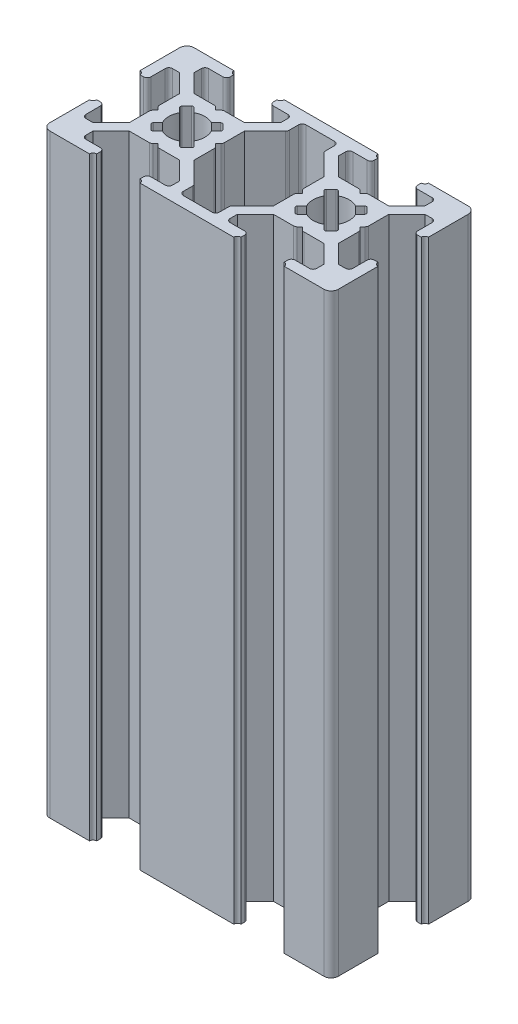
from build123d import *

# Parameters (mm, degrees)
BOSS_EXTRUDE1_DEPTH = 82.5
FILLET1_R           = 1
FILLET2_R           = 0.5
FILLET3_R           = 0.25
FILLET5_R           = 0.25
FILLET6_R           = 0.5
FILLET7_R           = 0.5
FILLET8_R           = 0.5


with BuildPart() as part:
    # Sketch2 → Boss-Extrude1 (new body)
    with BuildSketch(Plane(origin=(0, 0, 0), x_dir=(1, 0, 0), z_dir=(0, 1, 0))):
        with BuildLine():
            ThreePointArc((0, 13.5), (0.353553391, 13.353553391), (0.5, 13))
            Line((0.5, 13), (1.5, 13))
            Line((1.5, 13), (1.5, 16))
            Line((1.5, 16), (3, 16))
            Line((3, 16), (5.5, 13.5))
            Line((5.5, 13.5), (5.5, 10.5))
            Line((5.5, 10.5), (6, 10))
            Line((6, 10), (5.5, 9.5))
            Line((5.5, 9.5), (5.5, 6.5))
            Line((5.5, 6.5), (3, 4))
            Line((3, 4), (1.5, 4))
            Line((1.5, 4), (1.5, 7))
            Line((1.5, 7), (0.5, 7))
            ThreePointArc((0.5, 7), (0.353553391, 6.646446609), (0, 6.5))
            Line((0, 6.5), (0, 0))
            Line((0, 0), (6.5, 0))
            ThreePointArc((6.5, 0), (6.646446609, 0.353553391), (7, 0.5))
            Line((7, 0.5), (7, 1.5))
            Line((7, 1.5), (4, 1.5))
            Line((4, 1.5), (4, 3))
            Line((4, 3), (6.5, 5.5))
            Line((6.5, 5.5), (9.5, 5.5))
            Line((9.5, 5.5), (10, 6))
            Line((10, 6), (10.5, 5.5))
            Line((10.5, 5.5), (13.5, 5.5))
            Line((13.5, 5.5), (16, 3))
            Line((16, 3), (16, 1.5))
            Line((16, 1.5), (13, 1.5))
            Line((13, 1.5), (13, 0.5))
            ThreePointArc((13, 0.5), (13.353553391, 0.353553391), (13.5, 0))
            Line((13.5, 0), (26.5, 0))
            ThreePointArc((26.5, 0), (26.646446609, 0.353553391), (27, 0.5))
            Line((27, 0.5), (27, 1.5))
            Line((27, 1.5), (24, 1.5))
            Line((24, 1.5), (24, 3))
            Line((24, 3), (26.5, 5.5))
            Line((26.5, 5.5), (29.5, 5.5))
            Line((29.5, 5.5), (30, 6))
            Line((30, 6), (30.5, 5.5))
            Line((30.5, 5.5), (33.5, 5.5))
            Line((33.5, 5.5), (36, 3))
            Line((36, 3), (36, 1.5))
            Line((36, 1.5), (33, 1.5))
            Line((33, 1.5), (33, 0.5))
            ThreePointArc((33, 0.5), (33.353553391, 0.353553391), (33.5, 0))
            Line((33.5, 0), (40, 0))
            Line((40, 0), (40, 6.5))
            ThreePointArc((40, 6.5), (39.646446609, 6.646446609), (39.5, 7))
            Line((39.5, 7), (38.5, 7))
            Line((38.5, 7), (38.5, 4))
            Line((38.5, 4), (37, 4))
            Line((37, 4), (34.5, 6.5))
            Line((34.5, 6.5), (34.5, 9.5))
            Line((34.5, 9.5), (34, 10))
            Line((34, 10), (34.5, 10.5))
            Line((34.5, 10.5), (34.5, 13.5))
            Line((34.5, 13.5), (37, 16))
            Line((37, 16), (38.5, 16))
            Line((38.5, 16), (38.5, 13))
            Line((38.5, 13), (39.5, 13))
            ThreePointArc((39.5, 13), (39.646446609, 13.353553391), (40, 13.5))
            Line((40, 13.5), (40, 20))
            Line((40, 20), (33.5, 20))
            ThreePointArc((33.5, 20), (33.353553391, 19.646446609), (33, 19.5))
            Line((33, 19.5), (33, 18.5))
            Line((33, 18.5), (36, 18.5))
            Line((36, 18.5), (36, 17))
            Line((36, 17), (33.5, 14.5))
            Line((33.5, 14.5), (30.5, 14.5))
            Line((30.5, 14.5), (30, 14))
            Line((30, 14), (29.5, 14.5))
            Line((29.5, 14.5), (26.5, 14.5))
            Line((26.5, 14.5), (24, 17))
            Line((24, 17), (24, 18.5))
            Line((24, 18.5), (27, 18.5))
            Line((27, 18.5), (27, 19.5))
            ThreePointArc((27, 19.5), (26.646446609, 19.646446609), (26.5, 20))
            Line((26.5, 20), (13.5, 20))
            ThreePointArc((13.5, 20), (13.353553391, 19.646446609), (13, 19.5))
            Line((13, 19.5), (13, 18.5))
            Line((13, 18.5), (16, 18.5))
            Line((16, 18.5), (16, 17))
            Line((16, 17), (13.5, 14.5))
            Line((13.5, 14.5), (10.5, 14.5))
            Line((10.5, 14.5), (10, 14))
            Line((10, 14), (9.5, 14.5))
            Line((9.5, 14.5), (6.5, 14.5))
            Line((6.5, 14.5), (4, 17))
            Line((4, 17), (4, 18.5))
            Line((4, 18.5), (7, 18.5))
            Line((7, 18.5), (7, 19.5))
            ThreePointArc((7, 19.5), (6.646446609, 19.646446609), (6.5, 20))
            Line((6.5, 20), (0, 20))
            Line((0, 20), (0, 13.5))
        make_face()
        with BuildLine():
            Line((11.195582496, 12.195582496), (12, 13))
            Line((12, 13), (13, 12))
            Line((13, 12), (12.195582496, 11.195582496))
            ThreePointArc((12.195582496, 11.195582496), (12.422700584, 10.616864556), (12.5, 10))
            ThreePointArc((12.5, 10), (12.422700584, 9.383135444), (12.195582496, 8.804417504))
            Line((12.195582496, 8.804417504), (13, 8))
            Line((13, 8), (12, 7))
            Line((12, 7), (11.195582496, 7.804417504))
            ThreePointArc((11.195582496, 7.804417504), (10, 7.5), (8.804417504, 7.804417504))
            Line((8.804417504, 7.804417504), (8, 7))
            Line((8, 7), (7, 8))
            Line((7, 8), (7.804417504, 8.804417504))
            ThreePointArc((7.804417504, 8.804417504), (7.5, 10), (7.804417504, 11.195582496))
            Line((7.804417504, 11.195582496), (7, 12))
            Line((7, 12), (8, 13))
            Line((8, 13), (8.804417504, 12.195582496))
            ThreePointArc((8.804417504, 12.195582496), (10, 12.5), (11.195582496, 12.195582496))
        make_face(mode=Mode.SUBTRACT)
        Polygon((17.5, 16.5), (17.5, 18.5), (22.5, 18.5), (22.5, 16.5), (25.5, 13.5), (25.5, 10.5), (26, 10), (25.5, 9.5), (25.5, 6.5), (22.5, 3.5), (22.5, 1.5), (17.5, 1.5), (17.5, 3.5), (14.5, 6.5), (14.5, 9.5), (14, 10), (14.5, 10.5), (14.5, 13.5), align=None, mode=Mode.SUBTRACT)
        with BuildLine():
            Line((28.804417504, 7.804417504), (28, 7))
            Line((28, 7), (27, 8))
            Line((27, 8), (27.804417504, 8.804417504))
            ThreePointArc((27.804417504, 8.804417504), (27.5, 10), (27.804417504, 11.195582496))
            Line((27.804417504, 11.195582496), (27, 12))
            Line((27, 12), (28, 13))
            Line((28, 13), (28.804417504, 12.195582496))
            ThreePointArc((28.804417504, 12.195582496), (30, 12.5), (31.195582496, 12.195582496))
            Line((31.195582496, 12.195582496), (32, 13))
            Line((32, 13), (33, 12))
            Line((33, 12), (32.195582496, 11.195582496))
            ThreePointArc((32.195582496, 11.195582496), (32.422700584, 10.616864556), (32.5, 10))
            ThreePointArc((32.5, 10), (32.422700584, 9.383135444), (32.195582496, 8.804417504))
            Line((32.195582496, 8.804417504), (33, 8))
            Line((33, 8), (32, 7))
            Line((32, 7), (31.195582496, 7.804417504))
            ThreePointArc((31.195582496, 7.804417504), (30, 7.5), (28.804417504, 7.804417504))
        make_face(mode=Mode.SUBTRACT)
    extrude(amount=BOSS_EXTRUDE1_DEPTH)

    # Fillet1
    fillet1_edges = [part.edges().sort_by_distance(p)[0] for p in [
        (40, 41.25, 0),
        (0, 41.25, 0),
        (0, 41.25, -20),
        (40, 41.25, -20),
    ]]
    fillet(fillet1_edges, radius=FILLET1_R)

    # Fillet2
    fillet2_edges = [part.edges().sort_by_distance(p)[0] for p in [
        (7, 41.25, -18.5),
        (4, 41.25, -18.5),
        (9.5, 41.25, -14.5),
        (10.5, 41.25, -14.5),
        (16, 41.25, -18.5),
        (13, 41.25, -18.5),
    ]]
    fillet(fillet2_edges, radius=FILLET2_R)

    # Fillet3
    fillet3_edges = [part.edges().sort_by_distance(p)[0] for p in [
        (13, 41.25, -12),
        (12, 41.25, -13),
        (8, 41.25, -13),
        (7, 41.25, -12),
        (7, 41.25, -8),
        (8, 41.25, -7),
        (12, 41.25, -7),
        (13, 41.25, -8),
    ]]
    fillet(fillet3_edges, radius=FILLET3_R)

    # Fillet5
    fillet5_edges = [part.edges().sort_by_distance(p)[0] for p in [
        (27, 41.25, -8),
        (28, 41.25, -7),
        (32, 41.25, -7),
        (33, 41.25, -8),
        (33, 41.25, -12),
        (32, 41.25, -13),
        (28, 41.25, -13),
        (27, 41.25, -12),
    ]]
    fillet(fillet5_edges, radius=FILLET5_R)

    # Fillet6
    fillet6_edges = [part.edges().sort_by_distance(p)[0] for p in [
        (33, 41.25, -1.5),
        (36, 41.25, -1.5),
        (30.5, 41.25, -5.5),
        (29.5, 41.25, -5.5),
        (24, 41.25, -1.5),
        (27, 41.25, -1.5),
        (13, 41.25, -1.5),
        (16, 41.25, -1.5),
        (10.5, 41.25, -5.5),
        (9.5, 41.25, -5.5),
        (4, 41.25, -1.5),
        (7, 41.25, -1.5),
        (1.5, 41.25, -7),
        (1.5, 41.25, -4),
        (5.5, 41.25, -9.5),
        (5.5, 41.25, -10.5),
        (1.5, 41.25, -16),
        (1.5, 41.25, -13),
        (27, 41.25, -18.5),
        (24, 41.25, -18.5),
        (29.5, 41.25, -14.5),
        (30.5, 41.25, -14.5),
        (36, 41.25, -18.5),
        (33, 41.25, -18.5),
        (38.5, 41.25, -13),
        (38.5, 41.25, -16),
        (34.5, 41.25, -10.5),
        (34.5, 41.25, -9.5),
        (38.5, 41.25, -4),
        (38.5, 41.25, -7),
    ]]
    fillet(fillet6_edges, radius=FILLET6_R)

    # Fillet7
    fillet7_edges = [part.edges().sort_by_distance(p)[0] for p in [
        (22.5, 41.25, -16.5),
        (22.5, 41.25, -18.5),
        (17.5, 41.25, -18.5),
        (17.5, 41.25, -16.5),
        (17.5, 41.25, -3.5),
        (17.5, 41.25, -1.5),
        (22.5, 41.25, -1.5),
        (22.5, 41.25, -3.5),
    ]]
    fillet(fillet7_edges, radius=FILLET7_R)

    # Fillet8
    fillet8_edges = [part.edges().sort_by_distance(p)[0] for p in [
        (25.5, 41.25, -10.5),
        (14.5, 41.25, -10.5),
        (14.5, 41.25, -9.5),
        (25.5, 41.25, -9.5),
    ]]
    fillet(fillet8_edges, radius=FILLET8_R)


solid = part.part
